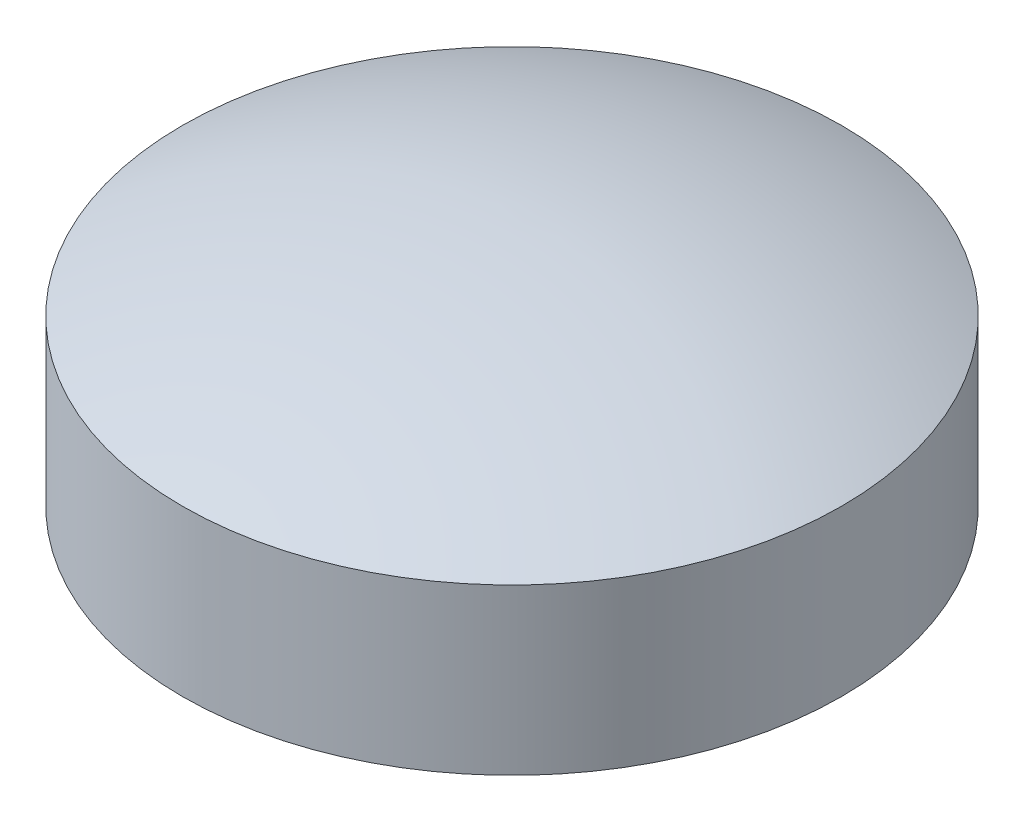
from build123d import *


with BuildPart() as part:
    # Skizze1 → Rotation1 (revolve)
    with BuildSketch(Plane.XY):
        with BuildLine():
            Line((-30, 28.245553203), (-30, 13.245553203))
            Line((-30, 13.245553203), (0, 13.245553203))
            Line((0, 13.245553203), (0, 35))
            ThreePointArc((0, 35), (-15.375488216, 33.290514437), (-30, 28.245553203))
        make_face()
    revolve(axis=Axis((0, 35, 0), (0, -1, 0)))


solid = part.part
